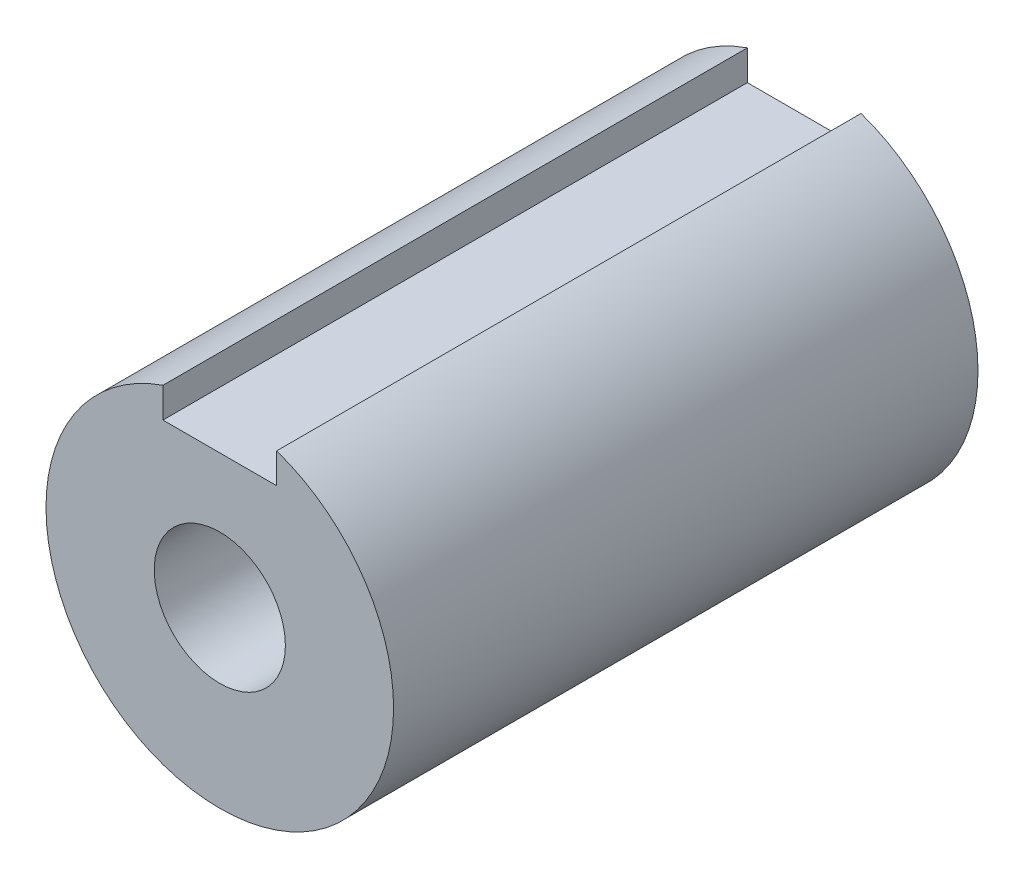
from build123d import *

# Parameters (mm, degrees)
ESQUISSE1_R             = 11.925
BOSS_EXTRU_1_DEPTH      = 40.1
ESQUISSE2_R             = 8.5
ENL_V_MAT_EXTRU_1_DEPTH = 9.77
ENL_V_MAT_EXTRU_2_DEPTH = 15.5
ESQUISSE5_R             = 4.5
ENL_V_MAT_EXTRU_3_DEPTH = 41.1
ENL_V_MAT_EXTRU_5_DEPTH = 41.1


with BuildPart() as part:
    # Esquisse1 → Boss.-Extru.1 (new body)
    with BuildSketch(Plane.XY):
        Circle(ESQUISSE1_R)
    extrude(amount=BOSS_EXTRU_1_DEPTH)

    # Esquisse2 → Enlèv. mat.-Extru.1 (cut)
    with BuildSketch(Plane.XY):
        Circle(ESQUISSE2_R)
    extrude(amount=ENL_V_MAT_EXTRU_1_DEPTH, mode=Mode.SUBTRACT)

    # Esquisse4 → Enlèv. mat.-Extru.2 (cut)
    with BuildSketch(Plane(origin=(0, 0, 9.77), x_dir=(-1, 0, 0), z_dir=(0, 0, -1))):
        with BuildLine():
            Line((-6.498055974, 5.479531783), (6.411422693, 5.580650415))
            ThreePointArc((6.411422693, 5.580650415), (0.066577592, -8.499739256), (-6.498055974, 5.479531783))
        make_face()
    extrude(amount=-ENL_V_MAT_EXTRU_2_DEPTH, mode=Mode.SUBTRACT)

    # Esquisse5 → Enlèv. mat.-Extru.3 (cut, through all)
    with BuildSketch(Plane.XY.offset(40.1)):
        Circle(ESQUISSE5_R)
    extrude(amount=-ENL_V_MAT_EXTRU_3_DEPTH, mode=Mode.SUBTRACT)

    # Esquisse6 → Enlèv. mat.-Extru.5 (cut, through all)
    with BuildSketch(Plane.XY.offset(40.1)):
        with BuildLine():
            Line((-3.9, 11.269233559), (-3.9, 9.199599168))
            Line((-3.9, 9.199599168), (3.9, 9.199599168))
            Line((3.9, 9.199599168), (3.9, 11.269233559))
            ThreePointArc((3.9, 11.269233559), (0, 11.925), (-3.9, 11.269233559))
        make_face()
    extrude(amount=-ENL_V_MAT_EXTRU_5_DEPTH, mode=Mode.SUBTRACT)


solid = part.part
